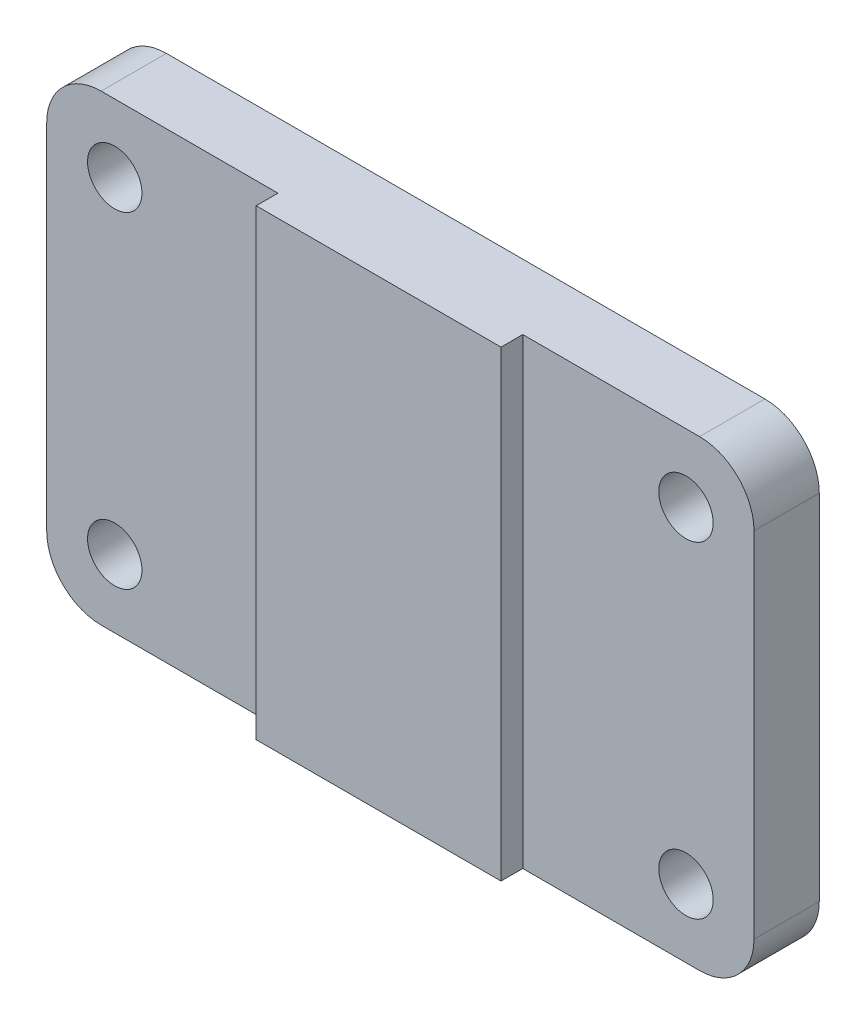
from build123d import *

# Parameters (mm, degrees)
EXTRUDE1_DEPTH          = 85
M10X1_25_TAPPED_HOLE1_D = 10
FILLET1_R               = 10
FILLET1_OF_MIRROR1_R    = 10


with BuildPart() as part:
    # Sketch1 → Extrude1 (new body)
    with BuildSketch(Plane(origin=(0, 0, 0), x_dir=(1, 0, 0), z_dir=(0, 1, 0))):
        Polygon((0, 0), (65, 0), (65, -12), (22.5, -12), (22.5, -16), (0, -16), align=None)
    extrude1 = extrude(amount=EXTRUDE1_DEPTH)

    # M10x1.25 Tapped Hole1 (through all)
    with Locations(Plane.XY.offset(12)):
        with Locations((52.5, 12.5), (52.5, 72.5)):
            m10x1_25_tapped_hole1 = Hole(M10X1_25_TAPPED_HOLE1_D / 2)

    # Fillet1
    fillet1_edges = [part.edges().sort_by_distance(p)[0] for p in [
        (65, 85, 6),
        (65, 0, 6),
    ]]
    fillet(fillet1_edges, radius=FILLET1_R)

    # Mirror1: Extrude1, M10x1.25 Tapped Hole1 across plane
    add(extrude1.mirror(Plane(origin=(0, 0, 0), x_dir=(0, 0, 1), z_dir=(1, 0, 0))))
    add(m10x1_25_tapped_hole1.mirror(Plane(origin=(0, 0, 0), x_dir=(0, 0, 1), z_dir=(1, 0, 0))), mode=Mode.SUBTRACT)

    # Fillet1 of Mirror1
    fillet1_of_mirror1_edges = [part.edges().sort_by_distance(p)[0] for p in [
        (-65, 85, 6),
        (-65, 0, 6),
    ]]
    fillet(fillet1_of_mirror1_edges, radius=FILLET1_OF_MIRROR1_R)


solid = part.part
